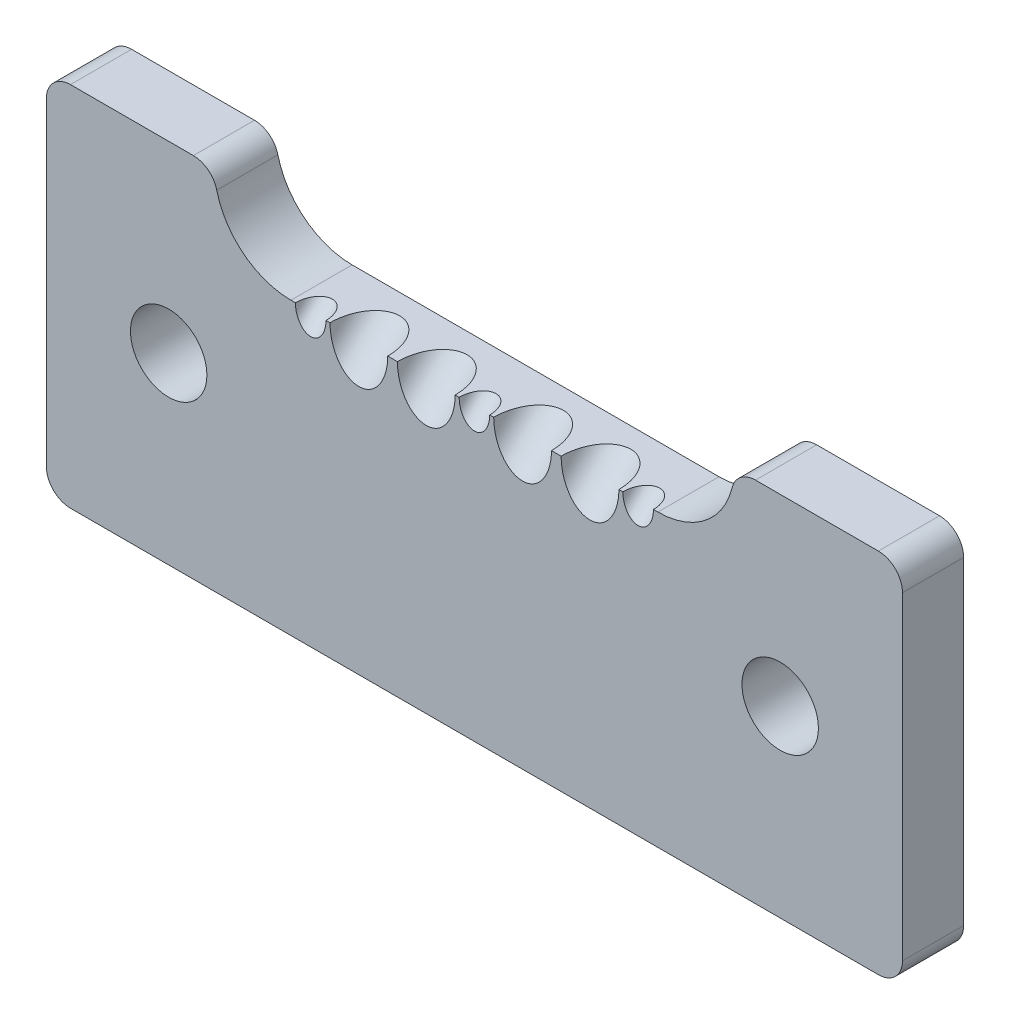
from build123d import *

# Parameters (mm, degrees)
SKETCH1_R               = 3.96875
BOSS_EXTRUDE1_DEPTH     = 6.35
SKETCH2_R               = 3
SKETCH2_R_2             = 1.5875
CUT_EXTRUDE1_DEPTH      = 22.326340521
CUT_EXTRUDE1_DEPTH_BACK = 11.104555903


with BuildPart() as part:
    # Sketch1 → Boss-Extrude1 (new body)
    with BuildSketch(Plane.XY):
        with BuildLine():
            ThreePointArc((17.691011583, 36.198659004), (20.503728332, 31.849390129), (25.4, 30.16))
            Line((25.4, 30.16), (63.5, 30.16))
            ThreePointArc((63.5, 30.16), (68.396271668, 31.849390129), (71.208988417, 36.198659004))
            ThreePointArc((71.208988417, 36.198659004), (72.094604522, 37.568076156), (73.636251773, 38.1))
            Line((73.636251773, 38.1), (86.4, 38.1))
            ThreePointArc((86.4, 38.1), (88.167766953, 37.367766953), (88.9, 35.6))
            Line((88.9, 35.6), (88.9, 2.5))
            ThreePointArc((88.9, 2.5), (88.167766953, 0.732233047), (86.4, 0))
            Line((86.4, 0), (2.5, 0))
            ThreePointArc((2.5, 0), (0.732233047, 0.732233047), (0, 2.5))
            Line((0, 2.5), (0, 35.6))
            ThreePointArc((0, 35.6), (0.732233047, 37.367766953), (2.5, 38.1))
            Line((2.5, 38.1), (15.263748227, 38.1))
            ThreePointArc((15.263748227, 38.1), (16.805395478, 37.568076156), (17.691011583, 36.198659004))
        make_face()
        with Locations((12.7, 19.05)):
            Circle(SKETCH1_R, mode=Mode.SUBTRACT)
        with Locations((76.2, 19.05)):
            Circle(SKETCH1_R, mode=Mode.SUBTRACT)
    extrude(amount=BOSS_EXTRUDE1_DEPTH)

    # Sketch2 → Cut-Extrude1 (cut, two sides)
    with BuildSketch(Plane(origin=(0, 11.905, -11.905), x_dir=(1, 0, 0), z_dir=(0, -0.707106781, 0.707106781))) as cut_extrude1_sk:
        with Locations((49.45, 25.816468581)):
            Circle(SKETCH2_R)
        with Locations((39.45, 25.816468581)):
            Circle(SKETCH2_R)
        with Locations((32.45, 25.816468581)):
            Circle(SKETCH2_R)
        with Locations((56.45, 25.816468581)):
            Circle(SKETCH2_R)
        with Locations((61.45, 25.816468581)):
            Circle(SKETCH2_R_2)
        with Locations((27.45, 25.816468581)):
            Circle(SKETCH2_R_2)
        with Locations((44.45, 25.816468581)):
            Circle(SKETCH2_R_2)
    extrude(amount=CUT_EXTRUDE1_DEPTH, mode=Mode.SUBTRACT)
    extrude(cut_extrude1_sk.sketch, amount=-CUT_EXTRUDE1_DEPTH_BACK, mode=Mode.SUBTRACT)


solid = part.part
